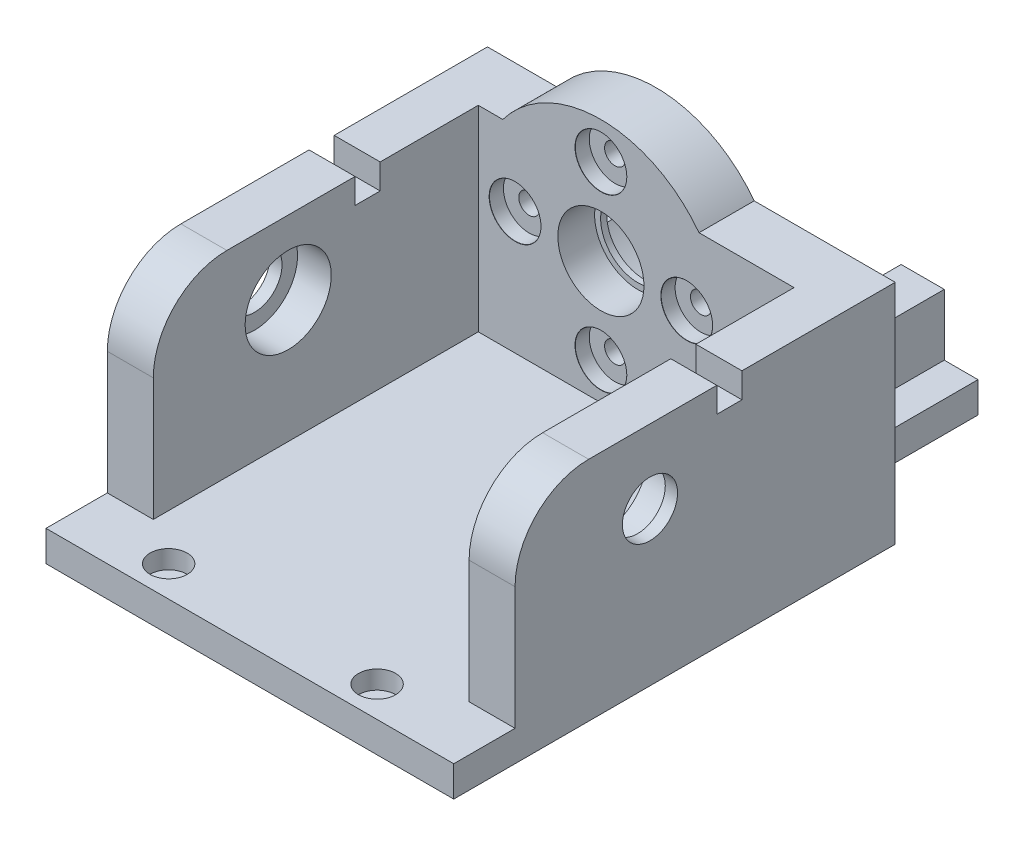
from build123d import *

# Parameters (mm, degrees)
SKETCH1_R                                     = 12
SKETCH1_R_2                                   = 7.025
BOSS_EXTRUDE1_DEPTH                           = 3
BOSS_EXTRUDE1_DEPTH_BACK                      = 3
SKETCH2_R                                     = 12
SKETCH2_R_2                                   = 7.025
BOSS_EXTRUDE2_DEPTH                           = 5
BOSS_EXTRUDE2_DEPTH_BACK                      = 5
BOSS_EXTRUDE3_DEPTH                           = 12
BOSS_EXTRUDE3_DEPTH_BACK                      = 12
SKETCH4_R                                     = 7.025
CUT_EXTRUDE1_DEPTH                            = 61.952850631
SKETCH5_R                                     = 7.025
CUT_EXTRUDE2_DEPTH                            = 65.437954654
SKETCH6_R                                     = 12
SKETCH6_R_2                                   = 6.05
BOSS_EXTRUDE4_DEPTH                           = 1
SKETCH7_R                                     = 11.35
BOSS_EXTRUDE5_DEPTH                           = 3
SKETCH8_R                                     = 20
SKETCH8_R_2                                   = 7.025
BOSS_EXTRUDE7_DEPTH                           = 6
CBORE_FOR_M3_HEX_HEAD_MACHINE_SCREW1_AT_COUNT = 2
CBORE_FOR_M3_HEX_HEAD_MACHINE_SCREW1_AT_PITCH = 19.798989873
CBORE_FOR_M3_HEX_HEAD_MACHINE_SCREW1_2_COUNT  = 2
CBORE_FOR_M3_HEX_HEAD_MACHINE_SCREW1_2_PITCH  = 19.798989873
CBORE_FOR_M3_HEX_HEAD_MACHINE_SCREW1_3_COUNT  = 2
CBORE_FOR_M3_HEX_HEAD_MACHINE_SCREW1_3_PITCH  = 28
BOSS_EXTRUDE8_DEPTH                           = 45
BOSS_EXTRUDE9_DEPTH                           = 35
SKETCH17_W                                    = 55
SKETCH17_H                                    = 83
BOSS_EXTRUDE10_DEPTH                          = 5
SKETCH18_W                                    = 7.5
SKETCH18_H                                    = 83
BOSS_EXTRUDE11_DEPTH                          = 35
SKETCH20_R                                    = 4
CUT_EXTRUDE3_DEPTH                            = 119.410303606
BOSS_EXTRUDE12_DEPTH                          = 13
BOSS_EXTRUDE14_REACH                          = 108.875
SKETCH23_W                                    = 10
SKETCH23_H                                    = 12
SKETCH24_W                                    = 7.5
SKETCH24_H                                    = 35
BOSS_EXTRUDE15_DEPTH                          = 6
SKETCH25_W                                    = 59
SKETCH25_H                                    = 5
BOSS_EXTRUDE16_DEPTH                          = 43
SKETCH26_R                                    = 7.025
BOSS_EXTRUDE17_DEPTH                          = 7.5
BOSS_EXTRUDE18_REACH                          = 123.566
SKETCH27_W                                    = 9
SKETCH27_H                                    = 12
BOSS_EXTRUDE19_DEPTH                          = 7.5
BOSS_EXTRUDE20_DEPTH                          = 2
SKETCH30_W                                    = 5
SKETCH30_H                                    = 10
CUT_EXTRUDE4_DEPTH                            = 116.957966522
LPATTERN2_COUNT                               = 5
LPATTERN2_PITCH                               = 15
BOSS_EXTRUDE25_REACH                          = 127.527
SKETCH35_W                                    = 3
SKETCH35_H                                    = 37
BOSS_EXTRUDE26_DEPTH                          = 10
BOSS_EXTRUDE27_REACH                          = 152.819
SKETCH37_W                                    = 10
SKETCH37_H                                    = 12
FILLET5_R                                     = 12
SKETCH40_W                                    = 69
SKETCH40_H                                    = 5
BOSS_EXTRUDE29_DEPTH                          = 10
SKETCH41_R                                    = 3.025
CUT_EXTRUDE6_DEPTH                            = 3
SKETCH42_W                                    = 7.5
SKETCH42_H                                    = 4.1
SKETCH42_W_2                                  = 10
CUT_EXTRUDE7_DEPTH                            = 4.1
SKETCH43_W                                    = 94.680867801
SKETCH43_H                                    = 163.733831536
CUT_EXTRUDE8_DEPTH                            = 106.561593395
SKETCH44_W                                    = 56.87239016
SKETCH44_H                                    = 32.880699015
CUT_EXTRUDE9_DEPTH                            = 55
SKETCH45_W                                    = 94.431579892
SKETCH45_H                                    = 50.480524865
CUT_EXTRUDE10_DEPTH                           = 2.5
SKETCH46_R                                    = 7.025
SKETCH46_R_2                                  = 4.5
BOSS_EXTRUDE30_DEPTH                          = 2
SKETCH47_R                                    = 7.025
SKETCH47_R_2                                  = 4.5
BOSS_EXTRUDE31_DEPTH                          = 2
SKETCH48_W                                    = 44
SKETCH48_H                                    = 25
CUT_EXTRUDE11_DEPTH                           = 10


with BuildPart() as part:
    # Sketch1 → Boss-Extrude1 (new, two sides)
    with BuildSketch(Plane.XY) as boss_extrude1_sk:
        Circle(SKETCH1_R)
        Circle(SKETCH1_R_2, mode=Mode.SUBTRACT)
    extrude(amount=BOSS_EXTRUDE1_DEPTH)
    extrude(boss_extrude1_sk.sketch, amount=-BOSS_EXTRUDE1_DEPTH_BACK)



with BuildPart() as body_2:
    # Sketch2 → Boss-Extrude2 (new, two sides)
    with BuildSketch(Plane(origin=(36.5, 0, 0), x_dir=(0, 0, -1), z_dir=(1, 0, 0))) as boss_extrude2_sk:
        with Locations((-34, 0)):
            Circle(SKETCH2_R)
        with Locations((-34, 0)):
            Circle(SKETCH2_R_2, mode=Mode.SUBTRACT)
    extrude(amount=BOSS_EXTRUDE2_DEPTH)
    extrude(boss_extrude2_sk.sketch, amount=-BOSS_EXTRUDE2_DEPTH_BACK)


with BuildPart() as part_1:
    add(part.part)

    add(body_2.part)  # Boss-Extrude3 merges body 2
    # Sketch3 → Boss-Extrude3 (add, two sides)
    with BuildSketch(Plane(origin=(0, 0, 0), x_dir=(1, 0, 0), z_dir=(0, 1, 0))) as boss_extrude3_sk:
        Polygon((0, -3), (31.5, -3), (31.5, -34), (41.5, -34), (41.5, 3), (0, 3), align=None)
    extrude(amount=BOSS_EXTRUDE3_DEPTH)
    extrude(boss_extrude3_sk.sketch, amount=-BOSS_EXTRUDE3_DEPTH_BACK)

    # Sketch4 → Cut-Extrude1 (cut, through all)
    with BuildSketch(Plane.XY.offset(3)):
        Circle(SKETCH4_R)
    extrude(amount=-CUT_EXTRUDE1_DEPTH, mode=Mode.SUBTRACT)

    # Sketch5 → Cut-Extrude2 (cut, through all)
    with BuildSketch(Plane.ZY.offset(-31.5)):
        with Locations(Location((34, 0, 0), (0, 0, 180))):
            Circle(SKETCH5_R)
    extrude(amount=-CUT_EXTRUDE2_DEPTH, mode=Mode.SUBTRACT)

    # Sketch6 → Boss-Extrude4 (add)
    with BuildSketch(Plane(origin=(0, 0, -3), x_dir=(-1, 0, 0), z_dir=(0, 0, -1))):
        with Locations(Location((0, 0, 0), (0, 0, 90))):
            Circle(SKETCH6_R)
        Circle(SKETCH6_R_2, mode=Mode.SUBTRACT)
    extrude(amount=BOSS_EXTRUDE4_DEPTH)

    # Sketch7 → Boss-Extrude5 (add)
    with BuildSketch(Plane(origin=(0, 0, -3), x_dir=(-1, 0, 0), z_dir=(0, 0, -1))):
        with BuildLine():
            Line((-20, 0), (-20, -20))
            Line((-20, -20), (20, -20))
            Line((20, -20), (20, 0))
            ThreePointArc((20, 0), (0, 20), (-20, 0))
        make_face()
        Circle(SKETCH7_R, mode=Mode.SUBTRACT)
    extrude(amount=BOSS_EXTRUDE5_DEPTH)

    # Sketch8 → Boss-Extrude7 (add)
    with BuildSketch(Plane.XY.offset(-3)):
        Circle(SKETCH8_R)
        Circle(SKETCH8_R_2, mode=Mode.SUBTRACT)
    extrude(amount=BOSS_EXTRUDE7_DEPTH)

    # Sketch10 → CBORE for M3 Hex Head Machine Screw1 (revolve, cut)
    with BuildSketch(Plane(origin=(-14, 0, 3), x_dir=(0, -1, 0), z_dir=(1, 0, 0))):
        Polygon((0, 0), (0, 14.021463052), (1.7, 13), (1.7, 2.3), (4.2, 2.3), (4.2, 0.025), (4.225, 0), align=None)
    cbore_for_m3_hex_head_machine_screw1 = revolve(axis=Axis((-14, 0, 9.35), (0, 0, -1)), mode=Mode.SUBTRACT)

    # CBORE for M3 Hex Head Machine Screw1 at: CBORE for M3 Hex Head Machine Screw1 ×2
    with Locations(*[Vector(0.7071067811865476, 0.7071067811865476, 0) * (i * CBORE_FOR_M3_HEX_HEAD_MACHINE_SCREW1_AT_PITCH) for i in range(1, CBORE_FOR_M3_HEX_HEAD_MACHINE_SCREW1_AT_COUNT)]):
        add(cbore_for_m3_hex_head_machine_screw1, mode=Mode.SUBTRACT)

    # CBORE for M3 Hex Head Machine Screw1 2: CBORE for M3 Hex Head Machine Screw1 ×2
    with Locations(*[Vector(0.7071067811865476, -0.7071067811865476, 0) * (i * CBORE_FOR_M3_HEX_HEAD_MACHINE_SCREW1_2_PITCH) for i in range(1, CBORE_FOR_M3_HEX_HEAD_MACHINE_SCREW1_2_COUNT)]):
        add(cbore_for_m3_hex_head_machine_screw1, mode=Mode.SUBTRACT)

    # CBORE for M3 Hex Head Machine Screw1 3: CBORE for M3 Hex Head Machine Screw1 ×2
    with Locations(*[(i * CBORE_FOR_M3_HEX_HEAD_MACHINE_SCREW1_3_PITCH, 0, 0) for i in range(1, CBORE_FOR_M3_HEX_HEAD_MACHINE_SCREW1_3_COUNT)]):
        add(cbore_for_m3_hex_head_machine_screw1, mode=Mode.SUBTRACT)

    # Sketch14 → Boss-Extrude8 (add)
    with BuildSketch(Plane(origin=(0, 0, -6), x_dir=(-1, 0, 0), z_dir=(0, 0, -1))):
        with BuildLine():
            Line((-20, 0), (-18, 0))
            ThreePointArc((-18, 0), (0, -18), (18, 0))
            Line((18, 0), (20, 0))
            Line((20, 0), (20, -20))
            Line((20, -20), (-20, -20))
            Line((-20, -20), (-20, 0))
        make_face()
    extrude(amount=BOSS_EXTRUDE8_DEPTH)

    # Sketch16 → Boss-Extrude9 (add)
    with BuildSketch(Plane(origin=(0, 0, -51), x_dir=(-1, 0, 0), z_dir=(0, 0, -1))):
        with BuildLine():
            Line((-18.7, 0), (-20, 0))
            Line((-20, 0), (-20, -20))
            Line((-20, -20), (20, -20))
            Line((20, -20), (20, 0))
            Line((20, 0), (18.7, 0))
            ThreePointArc((18.7, 0), (0, -18.7), (-18.7, 0))
        make_face()
    extrude(amount=BOSS_EXTRUDE9_DEPTH)

    # Sketch17 → Boss-Extrude10 (add)
    with BuildSketch(Plane.XZ.offset(20)):
        with Locations((0, -44.5)):
            Rectangle(SKETCH17_W, SKETCH17_H)
    extrude(amount=BOSS_EXTRUDE10_DEPTH)

    # Sketch18 → Boss-Extrude11 (add)
    with BuildSketch(Plane.XZ.offset(25)):
        with Locations((-23.75, -44.5)):
            Rectangle(SKETCH18_W, SKETCH18_H)
        with Locations((23.75, -44.5)):
            Rectangle(SKETCH18_W, SKETCH18_H)
    extrude(amount=BOSS_EXTRUDE11_DEPTH)

    # Sketch20 → Cut-Extrude3 (cut, through all)
    with BuildSketch(Plane(origin=(27.5, 0, 0), x_dir=(0, 0, -1), z_dir=(1, 0, 0))):
        with Locations((23.75, -45)):
            Circle(SKETCH20_R)
        with Locations((65.25, -45)):
            Circle(SKETCH20_R)
    extrude(amount=-CUT_EXTRUDE3_DEPTH, mode=Mode.SUBTRACT)

    # Sketch21 → Boss-Extrude12 (add)
    with BuildSketch(Plane.XZ.offset(12)):
        Polygon((31.5, 34), (31.5, 46), (41.5, 46), (41.5, 34), (41.5, -3), (20, -3), (16, -3), (16, 3), (31.5, 3), align=None)
    extrude(amount=BOSS_EXTRUDE12_DEPTH)

    # Sketch23 → Boss-Extrude14 (add, up to next)
    with BuildSketch(Plane(origin=(0, -12, 0), x_dir=(1, 0, 0), z_dir=(0, 1, 0)), mode=Mode.PRIVATE) as boss_extrude14_sk1:
        with Locations((36.5, -40)):
            Rectangle(SKETCH23_W, SKETCH23_H)
    boss_extrude14_tool1 = extrude(boss_extrude14_sk1.sketch, amount=BOSS_EXTRUDE14_REACH, mode=Mode.PRIVATE) - part_1.part
    add(boss_extrude14_tool1.solids().sort_by_distance((36.5, -12, 40))[0])

    # Sketch24 → Boss-Extrude15 (add)
    with BuildSketch(Plane.XY.offset(-3)):
        with Locations((23.75, -42.5)):
            Rectangle(SKETCH24_W, SKETCH24_H)
        with BuildLine():
            Line((16, -25), (16, -12))
            ThreePointArc((16, -12), (-6.32455532, -18.973665961), (-20, 0))
            Line((-20, 0), (-20, -20))
            Line((-20, -20), (-27.5, -20))
            Line((-27.5, -20), (-27.5, -60))
            Line((-27.5, -60), (-20, -60))
            Line((-20, -60), (-20, -25))
            Line((-20, -25), (16, -25))
        make_face()
    extrude(amount=BOSS_EXTRUDE15_DEPTH)

    # Sketch25 → Boss-Extrude16 (add)
    with BuildSketch(Plane.XY.offset(3)):
        with Locations((2, -22.5)):
            Rectangle(SKETCH25_W, SKETCH25_H)
    extrude(amount=BOSS_EXTRUDE16_DEPTH)

    # Sketch26 → Boss-Extrude17 (add)
    with BuildSketch(Plane.ZY.offset(20)):
        Polygon((34, 12), (-6, 12), (-6, -20), (46, -20), (56, -20), (56, 12), (46, 12), align=None)
        with Locations(Location((34, 0, 0), (0, 0, 180))):
            Circle(SKETCH26_R, mode=Mode.SUBTRACT)
    extrude(amount=BOSS_EXTRUDE17_DEPTH)

    # Sketch27 → Boss-Extrude18 (add, up to next)
    with BuildSketch(Plane(origin=(-20, 0, 0), x_dir=(0, 0, -1), z_dir=(1, 0, 0)), mode=Mode.PRIVATE) as boss_extrude18_sk1:
        with Locations((1.5, 6)):
            Rectangle(SKETCH27_W, SKETCH27_H)
    boss_extrude18_tool1 = extrude(boss_extrude18_sk1.sketch, amount=BOSS_EXTRUDE18_REACH, mode=Mode.PRIVATE) - part_1.part
    add(boss_extrude18_tool1.solids().sort_by_distance((-20, 6, -1.5))[0])

    # Sketch28 → Boss-Extrude19 (add)
    with BuildSketch(Plane.ZY.offset(27.5)):
        Polygon((46, -25), (3, -60), (3, -25), align=None)
    boss_extrude19 = extrude(amount=-BOSS_EXTRUDE19_DEPTH)

    # Mirror1: Boss-Extrude19 across plane
    add(boss_extrude19.mirror(Plane(origin=(0, 0, 0), x_dir=(0, 0, 1), z_dir=(1, 0, 0))))

    # Sketch29 → Boss-Extrude20 (add)
    with BuildSketch(Plane(origin=(20, 0, 0), x_dir=(0, 0, -1), z_dir=(1, 0, 0))):
        Polygon((3, 0), (3, -20), (86, -20), (86, 0), (6, 0), align=None)
    boss_extrude20 = extrude(amount=BOSS_EXTRUDE20_DEPTH)

    # Mirror2: Boss-Extrude20 across plane
    add(boss_extrude20.mirror(Plane(origin=(0, 0, 0), x_dir=(0, 0, 1), z_dir=(1, 0, 0))))

    # Sketch30 → Cut-Extrude4 (cut, through all)
    with BuildSketch(Plane(origin=(22, 0, 0), x_dir=(0, 0, -1), z_dir=(1, 0, 0))):
        with Locations((18.5, -5)):
            Rectangle(SKETCH30_W, SKETCH30_H)
    cut_extrude4 = extrude(amount=-CUT_EXTRUDE4_DEPTH, mode=Mode.SUBTRACT)

    # LPattern2: Cut-Extrude4 ×5
    with Locations(*[(0, 0, -i * LPATTERN2_PITCH) for i in range(1, LPATTERN2_COUNT)]):
        add(cut_extrude4, mode=Mode.SUBTRACT)

    # Sketch35 → Boss-Extrude25 (add, up to next)
    with BuildSketch(Plane(origin=(41.5, 0, 0), x_dir=(0, 0, -1), z_dir=(1, 0, 0)), mode=Mode.PRIVATE) as boss_extrude25_sk1:
        with Locations((4.5, -6.5)):
            Rectangle(SKETCH35_W, SKETCH35_H)
    boss_extrude25_tool1 = extrude(boss_extrude25_sk1.sketch, amount=-BOSS_EXTRUDE25_REACH, mode=Mode.PRIVATE) - part_1.part
    add(boss_extrude25_tool1.solids().sort_by_distance((41.5, -6.5, -4.5))[0])

    # Sketch36 → Boss-Extrude26 (add)
    with BuildSketch(Plane.XY.offset(46)):
        Polygon((41.5, 12), (31.5, 12), (31.5, -20), (-20, -20), (-27.5, -20), (-27.5, -25), (-20, -25), (20, -25), (27.5, -25), (41.5, -25), align=None)
    extrude(amount=BOSS_EXTRUDE26_DEPTH)

    # Sketch37 → Boss-Extrude27 (add, up to next)
    with BuildSketch(Plane(origin=(0, 0, 46), x_dir=(-1, 0, 0), z_dir=(0, 0, -1)), mode=Mode.PRIVATE) as boss_extrude27_sk1:
        with Locations((-36.5, 6)):
            Rectangle(SKETCH37_W, SKETCH37_H)
    boss_extrude27_tool1 = extrude(boss_extrude27_sk1.sketch, amount=BOSS_EXTRUDE27_REACH, mode=Mode.PRIVATE) - part_1.part
    add(boss_extrude27_tool1.solids().sort_by_distance((36.5, 6, 46))[0])

    # Fillet5
    fillet5_edges = [part_1.edges().sort_by_distance(p)[0] for p in [
        (-23.75, 12, 56),
        (36.5, 12, 56),
    ]]
    fillet(fillet5_edges, radius=FILLET5_R)

    # Sketch40 → Boss-Extrude29 (add)
    with BuildSketch(Plane.XY.offset(56)):
        with Locations((7, -22.5)):
            Rectangle(SKETCH40_W, SKETCH40_H)
    extrude(amount=BOSS_EXTRUDE29_DEPTH)

    # Sketch41 → Cut-Extrude6 (cut)
    with BuildSketch(Plane(origin=(0, -20, 0), x_dir=(1, 0, 0), z_dir=(0, 1, 0))):
        with Locations(Location((-12.5, -61, 0), (0, 0, 270))):
            Circle(SKETCH41_R)
        with Locations(Location((21.5, -61, 0), (0, 0, 270))):
            Circle(SKETCH41_R)
    extrude(amount=-CUT_EXTRUDE6_DEPTH, mode=Mode.SUBTRACT)

    # Sketch42 → Cut-Extrude7 (cut)
    with BuildSketch(Plane(origin=(0, 12, 0), x_dir=(1, 0, 0), z_dir=(0, 1, 0))):
        with Locations((-23.75, -21.05)):
            Rectangle(SKETCH42_W, SKETCH42_H)
        with Locations((36.5, -21.05)):
            Rectangle(SKETCH42_W_2, SKETCH42_H)
    extrude(amount=-CUT_EXTRUDE7_DEPTH, mode=Mode.SUBTRACT)

    # Sketch43 → Cut-Extrude8 (cut, through all)
    with BuildSketch(Plane.XZ.offset(25)):
        with Locations((10.203488009, -11.566149693)):
            Rectangle(SKETCH43_W, SKETCH43_H)
    extrude(amount=CUT_EXTRUDE8_DEPTH, mode=Mode.SUBTRACT)

    # Sketch44 → Cut-Extrude9 (cut)
    with BuildSketch(Plane(origin=(0, 0, -86), x_dir=(-1, 0, 0), z_dir=(0, 0, -1))):
        with Locations((0.206137448, -12.036265724)):
            Rectangle(SKETCH44_W, SKETCH44_H)
    extrude(amount=-CUT_EXTRUDE9_DEPTH, mode=Mode.SUBTRACT)

    # Sketch45 → Cut-Extrude10 (cut)
    with BuildSketch(Plane(origin=(41.5, 0, 0), x_dir=(0, 0, -1), z_dir=(1, 0, 0))):
        with Locations((-28.628182463, -5.975362977)):
            Rectangle(SKETCH45_W, SKETCH45_H)
    extrude(amount=-CUT_EXTRUDE10_DEPTH, mode=Mode.SUBTRACT)

    # Sketch46 → Boss-Extrude30 (add)
    with BuildSketch(Plane(origin=(39, 0, 0), x_dir=(0, 0, -1), z_dir=(1, 0, 0))):
        with Locations((-34, 0)):
            Circle(SKETCH46_R)
        with Locations((-34, 0)):
            Circle(SKETCH46_R_2, mode=Mode.SUBTRACT)
    extrude(amount=-BOSS_EXTRUDE30_DEPTH)

    # Sketch47 → Boss-Extrude31 (add)
    with BuildSketch(Plane.ZY.offset(27.5)):
        with Locations((34, 0)):
            Circle(SKETCH47_R)
        with Locations(Location((34, 0, 0), (0, 0, 180))):
            Circle(SKETCH47_R_2, mode=Mode.SUBTRACT)
    extrude(amount=-BOSS_EXTRUDE31_DEPTH)

    # Sketch48 → Cut-Extrude11 (cut)
    with BuildSketch(Plane(origin=(0, 0, 0), x_dir=(1, 0, 0), z_dir=(0, 1, 0))):
        with Locations((0, 18.5)):
            Rectangle(SKETCH48_W, SKETCH48_H)
    extrude(amount=-CUT_EXTRUDE11_DEPTH, mode=Mode.SUBTRACT)


solid = part_1.part
